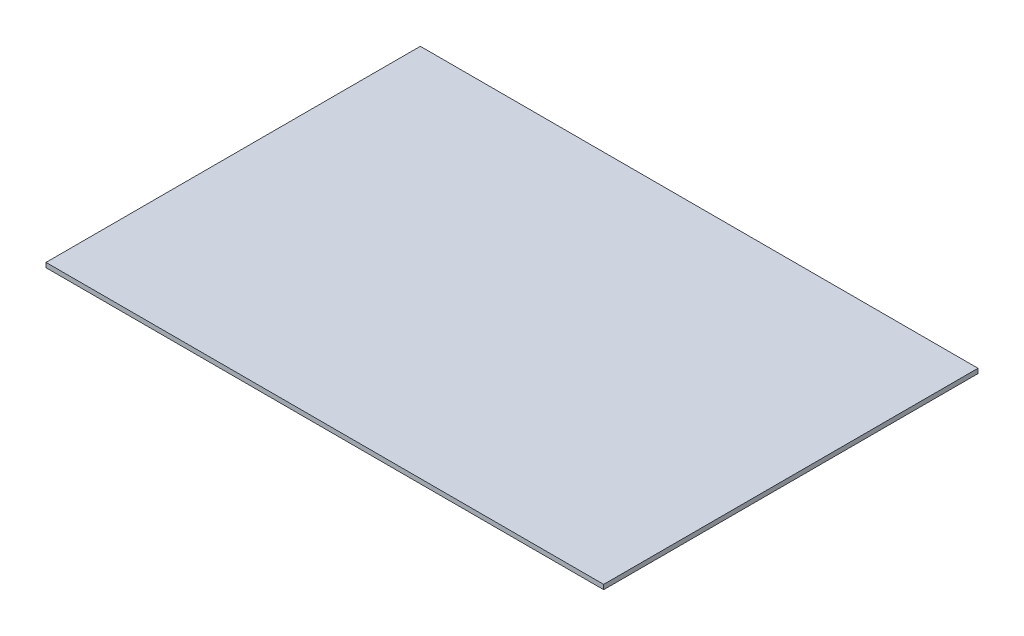
from build123d import *

# Parameters (mm, degrees)
SKETCH1_W           = 610.16
SKETCH1_H           = 409.54
BOSS_EXTRUDE1_DEPTH = 5.08


with BuildPart() as part:
    # Sketch1 → Boss-Extrude1 (new body)
    with BuildSketch(Plane(origin=(0, 0, 0), x_dir=(1, 0, 0), z_dir=(0, 1, 0))):
        with Locations((294.92, 194.61)):
            Rectangle(SKETCH1_W, SKETCH1_H)
    extrude(amount=BOSS_EXTRUDE1_DEPTH)


solid = part.part
